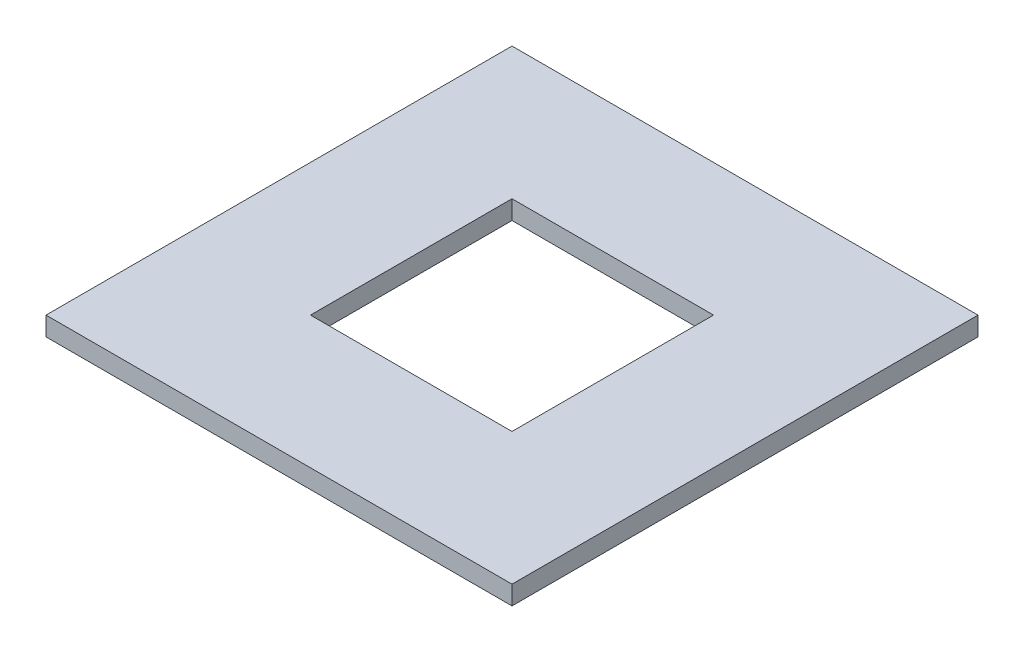
from build123d import *

# Parameters (mm, degrees)
SKETCH1_W           = 74
SKETCH1_H           = 74
SKETCH1_W_2         = 32
SKETCH1_H_2         = 32
BOSS_EXTRUDE1_DEPTH = 3
SKETCH3_R           = 1.8
CUT_EXTRUDE1_DEPTH  = 1.5


with BuildPart() as part:
    # Sketch1 → Boss-Extrude1 (new body)
    with BuildSketch(Plane(origin=(0, 0, 0), x_dir=(1, 0, 0), z_dir=(0, 1, 0))):
        Rectangle(SKETCH1_W, SKETCH1_H)
        Rectangle(SKETCH1_W_2, SKETCH1_H_2, mode=Mode.SUBTRACT)
    extrude(amount=BOSS_EXTRUDE1_DEPTH)

    # Sketch3 → Cut-Extrude1 (cut)
    with BuildSketch(Plane(origin=(0, 0, 0), x_dir=(1, 0, 0), z_dir=(0, 1, 0))):
        with Locations((-22, 22)):
            Circle(SKETCH3_R)
        with Locations((22, 22)):
            Circle(SKETCH3_R)
        with Locations((22, -22)):
            Circle(SKETCH3_R)
        with Locations((-22, -22)):
            Circle(SKETCH3_R)
    extrude(amount=CUT_EXTRUDE1_DEPTH, mode=Mode.SUBTRACT)


solid = part.part
